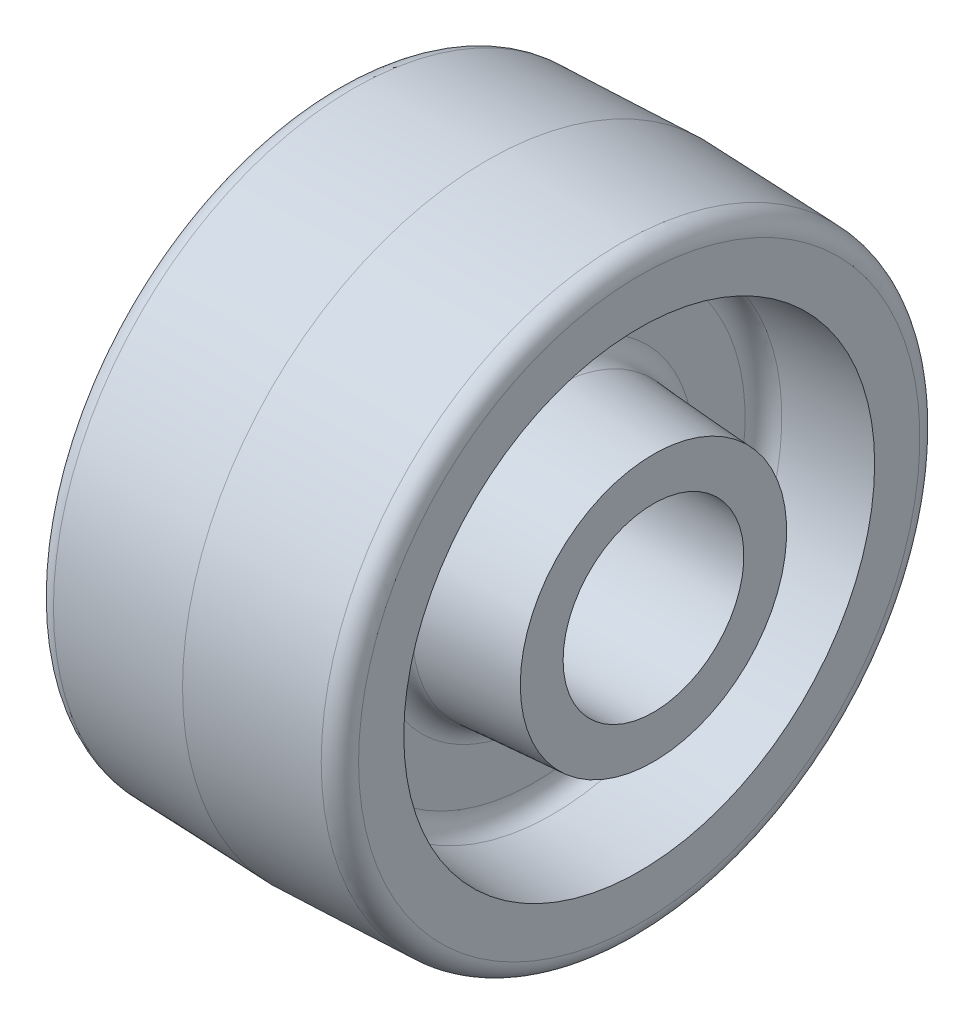
from build123d import *

# Parameters (mm, degrees)
ESBO_O2_W = 61.11875
ESBO_O2_H = 15.08125


with BuildPart() as part:
    # Esboço1 → Revolução1 (revolve)
    with BuildSketch(Plane.XY):
        with BuildLine():
            Line((-27.78125, 0), (-27.78125, 22.225))
            Line((-27.78125, 22.225), (-10.897657183, 23.370087151))
            ThreePointArc((-10.897657183, 23.370087151), (-8.792720814, 24.370034675), (-7.9375, 26.537809923))
            Line((-7.9375, 26.537809923), (-7.9375, 35.133042431))
            ThreePointArc((-7.9375, 35.133042431), (-8.792720814, 37.30081768), (-10.897657183, 38.300765204))
            Line((-10.897657183, 38.300765204), (-25.4, 39.284350072))
            Line((-25.4, 39.284350072), (-25.4, 46.827433348))
            ThreePointArc((-25.4, 46.827433348), (-24.509865997, 49.031976924), (-22.338574882, 50.00040132))
            Line((-22.338574882, 50.00040132), (0, 50.8))
            Line((0, 50.8), (22.338574882, 50.00040132))
            ThreePointArc((22.338574882, 50.00040132), (24.509865997, 49.031976924), (25.4, 46.827433348))
            Line((25.4, 46.827433348), (25.4, 39.284350072))
            Line((25.4, 39.284350072), (10.897657183, 38.300765204))
            ThreePointArc((10.897657183, 38.300765204), (8.792720814, 37.30081768), (7.9375, 35.133042431))
            Line((7.9375, 35.133042431), (7.9375, 26.537809923))
            ThreePointArc((7.9375, 26.537809923), (8.792720814, 24.370034675), (10.897657183, 23.370087151))
            Line((10.897657183, 23.370087151), (27.78125, 22.225))
            Line((27.78125, 22.225), (27.78125, 0))
            Line((27.78125, 0), (-27.78125, 0))
        make_face()
    revolve(axis=Axis((27.78125, 0, 0), (-1, 0, 0)))

    # Esboço2 → Corte-Revolução1 (revolve, cut)
    with BuildSketch(Plane.XY):
        with Locations((0, 7.540625)):
            Rectangle(ESBO_O2_W, ESBO_O2_H)
    revolve(axis=Axis((30.559375, 0, 0), (-1, 0, 0)), mode=Mode.SUBTRACT)


solid = part.part
